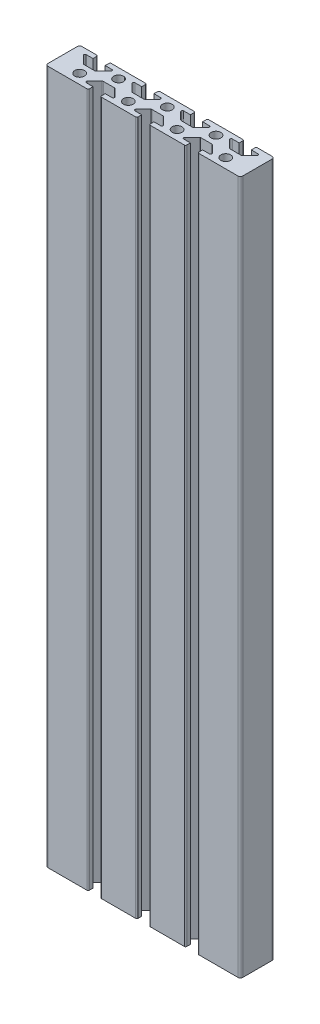
from build123d import *

# Parameters (mm, degrees)
SKETCH1_R           = 2
BOSS_EXTRUDE1_DEPTH = 285
FILLET1_R           = 0.5
FILLET2_R           = 0.5
FILLET3_R           = 1
SKETCH2_R           = 2.5
CUT_EXTRUDE2_DEPTH  = 230
SKETCH3_R           = 5.5
CUT_EXTRUDE3_DEPTH  = 7
SKETCH4_R           = 2.5
CUT_EXTRUDE4_DEPTH  = 7
SKETCH5_R           = 5.5
CUT_EXTRUDE5_DEPTH  = 7


with BuildPart() as part:
    # Sketch1 → Boss-Extrude1 (new body)
    with BuildSketch(Plane(origin=(0, 0, 0), x_dir=(1, 0, 0), z_dir=(0, 1, 0))):
        Polygon((67.5, 8), (63.5, 12), (67.5, 12), (67.5, 14), (52.5, 14), (52.5, 12), (56.5, 12), (52.5, 8), (47.5, 8), (43.5, 12), (47.5, 12), (47.5, 14), (32.5, 14), (32.5, 12), (36.5, 12), (32.5, 8), (27.5, 8), (23.5, 12), (27.5, 12), (27.5, 14), (12.5, 14), (12.5, 12), (16.5, 12), (12.5, 8), (7.5, 8), (3.5, 12), (7.5, 12), (7.5, 14), (0, 14), (0, 0), (17.5, 0), (17.5, 2), (13.5, 2), (17.5, 6), (22.5, 6), (26.5, 2), (22.5, 2), (22.5, 0), (37.5, 0), (37.5, 2), (33.5, 2), (37.5, 6), (42.5, 6), (46.5, 2), (42.5, 2), (42.5, 0), (57.5, 0), (57.5, 2), (53.5, 2), (57.5, 6), (62.5, 6), (66.5, 2), (62.5, 2), (62.5, 0), (80, 0), (80, 14), (72.5, 14), (72.5, 12), (76.5, 12), (72.5, 8), align=None)
        with Locations((10, 4)):
            Circle(SKETCH1_R, mode=Mode.SUBTRACT)
        with Locations((30, 4)):
            Circle(SKETCH1_R, mode=Mode.SUBTRACT)
        with Locations((50, 4)):
            Circle(SKETCH1_R, mode=Mode.SUBTRACT)
        with Locations((70, 4)):
            Circle(SKETCH1_R, mode=Mode.SUBTRACT)
        with Locations((20, 10)):
            Circle(SKETCH1_R, mode=Mode.SUBTRACT)
        with Locations((40, 10)):
            Circle(SKETCH1_R, mode=Mode.SUBTRACT)
        with Locations((60, 10)):
            Circle(SKETCH1_R, mode=Mode.SUBTRACT)
    extrude(amount=BOSS_EXTRUDE1_DEPTH)

    # Fillet1
    fillet1_edges = [part.edges().sort_by_distance(p)[0] for p in [
        (7.5, 142.5, -14),
        (3.5, 142.5, -12),
        (7.5, 142.5, -8),
        (12.5, 142.5, -8),
        (16.5, 142.5, -12),
        (12.5, 142.5, -14),
        (27.5, 142.5, -14),
        (23.5, 142.5, -12),
        (27.5, 142.5, -8),
        (32.5, 142.5, -8),
        (36.5, 142.5, -12),
        (32.5, 142.5, -14),
        (47.5, 142.5, -14),
        (43.5, 142.5, -12),
        (47.5, 142.5, -8),
        (52.5, 142.5, -8),
        (56.5, 142.5, -12),
        (52.5, 142.5, -14),
        (67.5, 142.5, -14),
        (63.5, 142.5, -12),
        (67.5, 142.5, -8),
        (72.5, 142.5, -8),
        (76.5, 142.5, -12),
        (72.5, 142.5, -14),
    ]]
    fillet(fillet1_edges, radius=FILLET1_R)

    # Fillet2
    fillet2_edges = [part.edges().sort_by_distance(p)[0] for p in [
        (26.5, 142.5, -2),
        (22.5, 142.5, -6),
        (17.5, 142.5, -6),
        (13.5, 142.5, -2),
        (17.5, 142.5, 0),
        (62.5, 142.5, 0),
        (66.5, 142.5, -2),
        (62.5, 142.5, -6),
        (57.5, 142.5, -6),
        (53.5, 142.5, -2),
        (57.5, 142.5, 0),
        (42.5, 142.5, 0),
        (46.5, 142.5, -2),
        (42.5, 142.5, -6),
        (37.5, 142.5, -6),
        (33.5, 142.5, -2),
        (37.5, 142.5, 0),
        (22.5, 142.5, 0),
    ]]
    fillet(fillet2_edges, radius=FILLET2_R)

    # Fillet3
    fillet3_edges = [part.edges().sort_by_distance(p)[0] for p in [
        (0, 142.5, 0),
        (0, 142.5, -14),
        (80, 142.5, -14),
        (80, 142.5, 0),
    ]]
    fillet(fillet3_edges, radius=FILLET3_R)

    # Sketch2 → Cut-Extrude2 (cut)
    with BuildSketch(Plane(origin=(0, 0, -14), x_dir=(-1, 0, 0), z_dir=(0, 0, -1))):
        with Locations((-40, 10)):
            Circle(SKETCH2_R)
    extrude(amount=-CUT_EXTRUDE2_DEPTH, mode=Mode.SUBTRACT)

    # Sketch3 → Cut-Extrude3 (cut)
    with BuildSketch(Plane(origin=(0, 0, -14), x_dir=(-1, 0, 0), z_dir=(0, 0, -1))):
        with Locations((-40, 10)):
            Circle(SKETCH3_R)
    extrude(amount=-CUT_EXTRUDE3_DEPTH, mode=Mode.SUBTRACT)

    # Sketch4 → Cut-Extrude4 (cut)
    with BuildSketch(Plane(origin=(0, 0, -14), x_dir=(-1, 0, 0), z_dir=(0, 0, -1))):
        with Locations((-40, 275)):
            Circle(SKETCH4_R)
    extrude(amount=-CUT_EXTRUDE4_DEPTH, mode=Mode.SUBTRACT)

    # Sketch5 → Cut-Extrude5 (cut)
    with BuildSketch(Plane(origin=(0, 0, -14), x_dir=(-1, 0, 0), z_dir=(0, 0, -1))):
        with Locations((-40, 275)):
            Circle(SKETCH5_R)
    extrude(amount=-CUT_EXTRUDE5_DEPTH, mode=Mode.SUBTRACT)


solid = part.part
